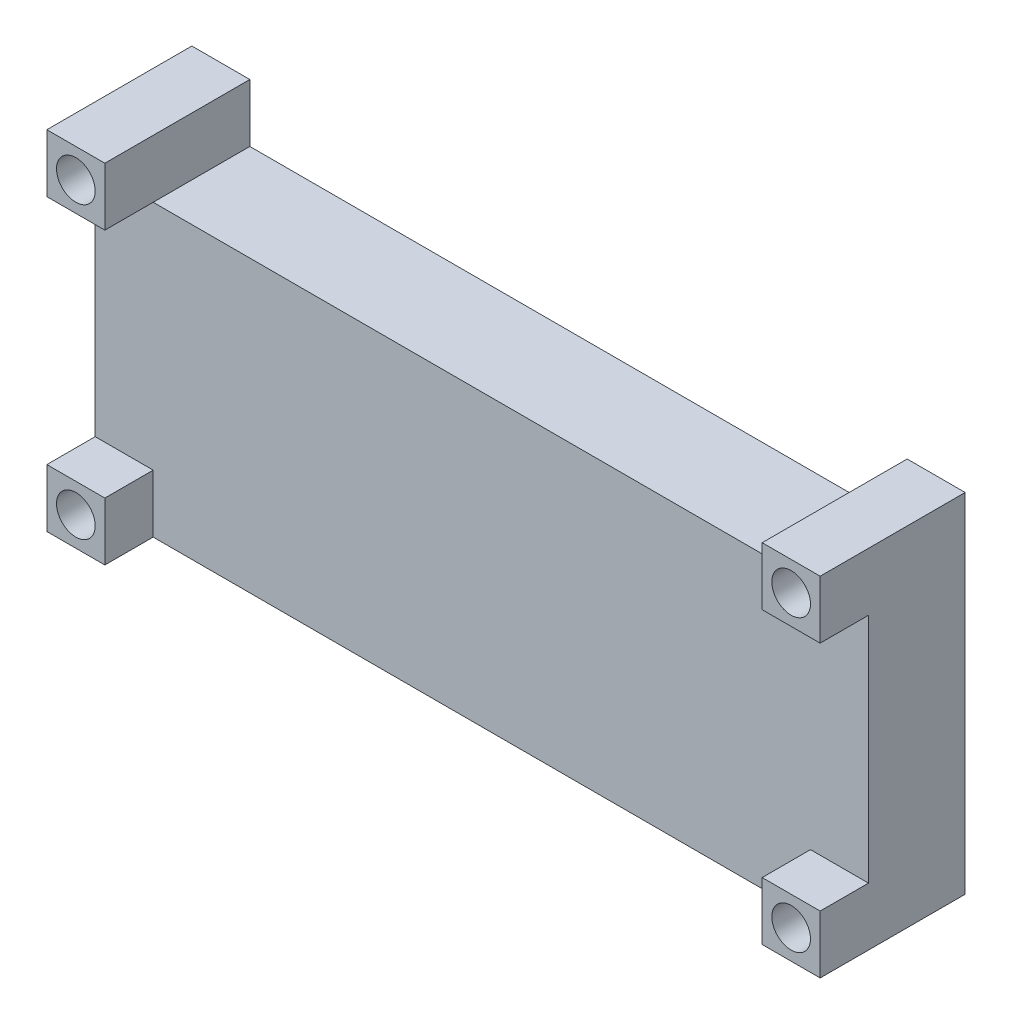
from build123d import *

# Parameters (mm, degrees)
BOSS_EXTRUDE1_DEPTH  = 10
SKETCH2_W            = 6
SKETCH2_H            = 6
SKETCH2_R            = 2
BOSS_EXTRUDE2_DEPTH  = 5
SKETCH2_2_R          = 2
CUT_EXTRUDE1_DEPTH   = 89.294960219
LPATTERN2_COUNT      = 2
LPATTERN2_PITCH      = 74
LPATTERN2_COUNT_DIR2 = 2
LPATTERN2_PITCH_DIR2 = 30


with BuildPart() as part:
    # Sketch1 → Boss-Extrude1 (new body)
    with BuildSketch(Plane.XY):
        Polygon((0, 36), (6, 36), (6, 30), (74, 30), (74, 36), (80, 36), (80, 0), (0, 0), align=None)
    extrude(amount=BOSS_EXTRUDE1_DEPTH)

    # Sketch2 → Boss-Extrude2 (add)
    with BuildSketch(Plane.XY.offset(10)):
        with Locations((3, 33)):
            Rectangle(SKETCH2_W, SKETCH2_H)
        with Locations((3, 33)):
            Circle(SKETCH2_R, mode=Mode.SUBTRACT)
    boss_extrude2 = extrude(amount=BOSS_EXTRUDE2_DEPTH)

    # Sketch2_2 → Cut-Extrude1 (cut, through all)
    with BuildSketch(Plane.XY.offset(10)):
        with Locations((3, 33)):
            Circle(SKETCH2_2_R)
    cut_extrude1 = extrude(amount=-CUT_EXTRUDE1_DEPTH, mode=Mode.SUBTRACT)

    # LPattern2: Boss-Extrude2, Cut-Extrude1 2 × 2
    with Locations(*[(i * LPATTERN2_PITCH, -j * LPATTERN2_PITCH_DIR2, 0) for i in range(LPATTERN2_COUNT) for j in range(LPATTERN2_COUNT_DIR2) if (i, j) != (0, 0)]):
        add(boss_extrude2)
        add(cut_extrude1, mode=Mode.SUBTRACT)


solid = part.part
